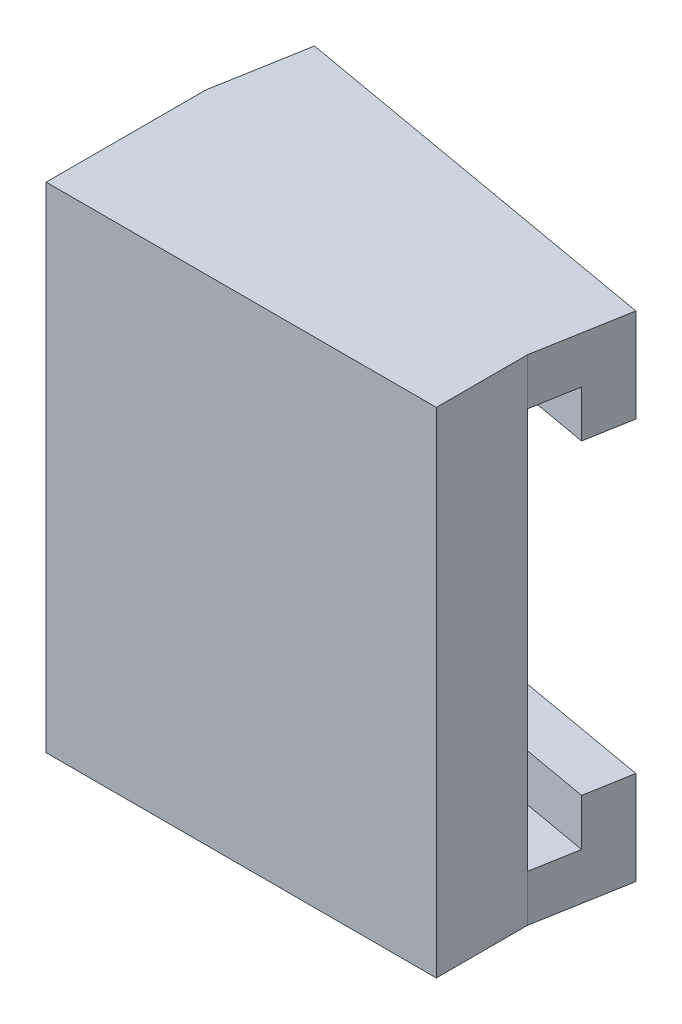
from build123d import *

# Parameters (mm, degrees)
SKIZZE1_W                       = 15
SKIZZE1_H                       = 19
AUFSATZ_LINEAR_AUSTRAGEN1_DEPTH = 3
AUFSATZ_LINEAR_AUSTRAGEN2_DEPTH = 19
SKIZZE5_R                       = 3
SCHNITT_LINEAR_AUSTRAGEN1_DEPTH = 3
SKIZZE6_W                       = 15
SKIZZE6_H                       = 19
AUFSATZ_LINEAR_AUSTRAGEN3_DEPTH = 0.5
SKIZZE7_W                       = 15.231399179
SKIZZE7_H                       = 1.8
AUFSATZ_LINEAR_AUSTRAGEN4_DEPTH = 3.6
AUFSATZ_LINEAR_AUSTRAGEN5_DEPTH = 1.8
AUFSATZ_LINEAR_AUSTRAGEN6_DEPTH = 1.8


with BuildPart() as part:
    # Skizze1 → Aufsatz-Linear austragen1 (new body)
    with BuildSketch(Plane.XY):
        Rectangle(SKIZZE1_W, SKIZZE1_H)
    extrude(amount=AUFSATZ_LINEAR_AUSTRAGEN1_DEPTH)

    # Skizze3 → Aufsatz-Linear austragen2 (add)
    with BuildSketch(Plane(origin=(0, 9.5, 0), x_dir=(1, 0, 0), z_dir=(0, 1, 0))):
        Polygon((-7.5, 0), (-7.5, 2.644904711), (7.5, 0), align=None)
    extrude(amount=-AUFSATZ_LINEAR_AUSTRAGEN2_DEPTH)

    # Skizze5 → Schnitt-Linear austragen1 (cut)
    with BuildSketch(Plane.XY.offset(3)):
        Circle(SKIZZE5_R)
    extrude(amount=-SCHNITT_LINEAR_AUSTRAGEN1_DEPTH, mode=Mode.SUBTRACT)

    # Skizze6 → Aufsatz-Linear austragen3 (add)
    with BuildSketch(Plane.XY.offset(3)):
        Rectangle(SKIZZE6_W, SKIZZE6_H)
    extrude(amount=AUFSATZ_LINEAR_AUSTRAGEN3_DEPTH)

    # Skizze7 → Aufsatz-Linear austragen4 (add)
    with BuildSketch(Plane(origin=(0.226152672, 0, -1.282575537), x_dir=(-0.984807753, 0, -0.173648178), z_dir=(0.173648178, 0, -0.984807753))):
        with Locations((0.229641442, 8.6)):
            Rectangle(SKIZZE7_W, SKIZZE7_H)
        with Locations((0.229641442, -8.6)):
            Rectangle(SKIZZE7_W, SKIZZE7_H)
    extrude(amount=AUFSATZ_LINEAR_AUSTRAGEN4_DEPTH)

    # Skizze10 → Aufsatz-Linear austragen5 (add)
    with BuildSketch(Plane.XZ.offset(-7.7)):
        Polygon((8.12513344, -3.545307911), (7.81256672, -1.772653955), (-7.18743328, -4.417558666), (-6.87486656, -6.190212621), align=None)
    extrude(amount=AUFSATZ_LINEAR_AUSTRAGEN5_DEPTH)

    # Skizze9 → Aufsatz-Linear austragen6 (add)
    with BuildSketch(Plane(origin=(0, -7.7, 0), x_dir=(1, 0, 0), z_dir=(0, 1, 0))):
        Polygon((7.81256672, 1.772653955), (-7.18743328, 4.417558666), (-6.87486656, 6.190212621), (8.12513344, 3.545307911), align=None)
    extrude(amount=AUFSATZ_LINEAR_AUSTRAGEN6_DEPTH)


solid = part.part
